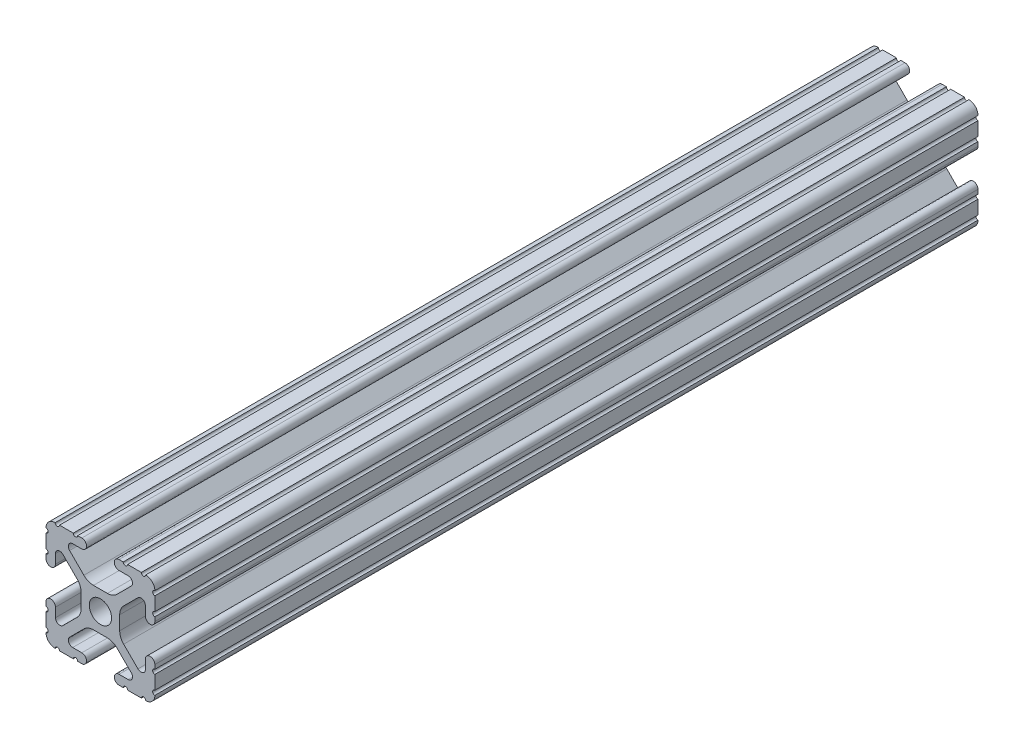
from build123d import *

# Parameters (mm, degrees)
SKETCH1_R           = 2.6035
BOSS_EXTRUDE1_DEPTH = 96.04375


with BuildPart() as part:
    # Sketch1 → Boss-Extrude1 (new body, symmetric)
    with BuildSketch(Plane(origin=(0, 0, -450.85), x_dir=(-1, 0, 0), z_dir=(0, 0, -1))):
        with BuildLine():
            Line((12.7, -9.5504), (12.7, -6.3330836))
            ThreePointArc((12.7, -6.3330836), (12.192, -5.8250836), (12.7, -5.3170836))
            Line((12.7, -5.3170836), (12.7, -4.3434))
            ThreePointArc((12.7, -4.3434), (11.5951, -3.2385), (10.4902, -4.3434))
            Line((10.4902, -4.3434), (10.4902, -6.474794456))
            ThreePointArc((10.4902, -6.474794456), (9.863006367, -7.413456061), (8.75577951, -7.193214945))
            Line((8.75577951, -7.193214945), (5.42573597, -3.863171405))
            ThreePointArc((5.42573597, -3.863171405), (4.737482484, -2.833127272), (4.4958, -1.618107374))
            Line((4.4958, -1.618107374), (4.4958, 1.618107374))
            ThreePointArc((4.4958, 1.618107374), (4.737482484, 2.833127272), (5.42573597, 3.863171405))
            Line((5.42573597, 3.863171405), (8.75577951, 7.193214945))
            ThreePointArc((8.75577951, 7.193214945), (9.863006367, 7.413456061), (10.4902, 6.474794456))
            Line((10.4902, 6.474794456), (10.4902, 4.343399971))
            ThreePointArc((10.4902, 4.343399971), (11.5951, 3.238499971), (12.7, 4.343399971))
            Line((12.7, 4.343399971), (12.7, 5.3170836))
            ThreePointArc((12.7, 5.3170836), (12.192, 5.8250836), (12.7, 6.3330836))
            Line((12.7, 6.3330836), (12.7, 9.5504))
            ThreePointArc((12.7, 9.5504), (12.192000006, 10.058323491), (12.699846982, 10.566399977))
            ThreePointArc((12.699846982, 10.566399977), (12.082522516, 12.082522516), (10.566399977, 12.699846982))
            ThreePointArc((10.566399977, 12.699846982), (10.058323491, 12.192000006), (9.5504, 12.7))
            Line((9.5504, 12.7), (6.3330836, 12.7))
            ThreePointArc((6.3330836, 12.7), (5.8250836, 12.192), (5.3170836, 12.7))
            Line((5.3170836, 12.7), (4.3434, 12.7))
            ThreePointArc((4.3434, 12.7), (3.2385, 11.5951), (4.3434, 10.4902))
            Line((4.3434, 10.4902), (6.474794456, 10.4902))
            ThreePointArc((6.474794456, 10.4902), (7.413456061, 9.863006367), (7.193214945, 8.75577951))
            Line((7.193214945, 8.75577951), (3.863171405, 5.42573597))
            ThreePointArc((3.863171405, 5.42573597), (2.833127272, 4.737482484), (1.618107374, 4.4958))
            Line((1.618107374, 4.4958), (-1.618107374, 4.4958))
            ThreePointArc((-1.618107374, 4.4958), (-2.833127272, 4.737482484), (-3.863171405, 5.42573597))
            Line((-3.863171405, 5.42573597), (-7.193214945, 8.75577951))
            ThreePointArc((-7.193214945, 8.75577951), (-7.413456061, 9.863006367), (-6.474794456, 10.4902))
            Line((-6.474794456, 10.4902), (-4.343399971, 10.4902))
            ThreePointArc((-4.343399971, 10.4902), (-3.238499971, 11.5951), (-4.343399971, 12.7))
            Line((-4.343399971, 12.7), (-5.3170836, 12.7))
            ThreePointArc((-5.3170836, 12.7), (-5.8250836, 12.192), (-6.3330836, 12.7))
            Line((-6.3330836, 12.7), (-9.5504, 12.7))
            ThreePointArc((-9.5504, 12.7), (-10.058323491, 12.192000006), (-10.566399977, 12.699846982))
            ThreePointArc((-10.566399977, 12.699846982), (-12.082522516, 12.082522516), (-12.699846982, 10.566399977))
            ThreePointArc((-12.699846982, 10.566399977), (-12.192000006, 10.058323491), (-12.7, 9.5504))
            Line((-12.7, 9.5504), (-12.7, 6.3330836))
            ThreePointArc((-12.7, 6.3330836), (-12.192, 5.8250836), (-12.7, 5.3170836))
            Line((-12.7, 5.3170836), (-12.7, 4.3434))
            ThreePointArc((-12.7, 4.3434), (-11.5951, 3.2385), (-10.4902, 4.3434))
            Line((-10.4902, 4.3434), (-10.4902, 6.474794456))
            ThreePointArc((-10.4902, 6.474794456), (-9.863006367, 7.413456061), (-8.75577951, 7.193214945))
            Line((-8.75577951, 7.193214945), (-5.42573597, 3.863171405))
            ThreePointArc((-5.42573597, 3.863171405), (-4.737482484, 2.833127272), (-4.4958, 1.618107374))
            Line((-4.4958, 1.618107374), (-4.4958, -1.618107374))
            ThreePointArc((-4.4958, -1.618107374), (-4.737482484, -2.833127272), (-5.42573597, -3.863171405))
            Line((-5.42573597, -3.863171405), (-8.75577951, -7.193214945))
            ThreePointArc((-8.75577951, -7.193214945), (-9.863006367, -7.413456061), (-10.4902, -6.474794456))
            Line((-10.4902, -6.474794456), (-10.4902, -4.343399971))
            ThreePointArc((-10.4902, -4.343399971), (-11.5951, -3.238499971), (-12.7, -4.343399971))
            Line((-12.7, -4.343399971), (-12.7, -5.3170836))
            ThreePointArc((-12.7, -5.3170836), (-12.192, -5.8250836), (-12.7, -6.3330836))
            Line((-12.7, -6.3330836), (-12.7, -9.5504))
            ThreePointArc((-12.7, -9.5504), (-12.192000006, -10.058323491), (-12.699846982, -10.566399977))
            ThreePointArc((-12.699846982, -10.566399977), (-12.082522516, -12.082522516), (-10.566399977, -12.699846982))
            ThreePointArc((-10.566399977, -12.699846982), (-10.058323491, -12.192000006), (-9.5504, -12.7))
            Line((-9.5504, -12.7), (-6.3330836, -12.7))
            ThreePointArc((-6.3330836, -12.7), (-5.8250836, -12.192), (-5.3170836, -12.7))
            Line((-5.3170836, -12.7), (-4.3434, -12.7))
            ThreePointArc((-4.3434, -12.7), (-3.2385, -11.5951), (-4.3434, -10.4902))
            Line((-4.3434, -10.4902), (-6.474794456, -10.4902))
            ThreePointArc((-6.474794456, -10.4902), (-7.413456061, -9.863006367), (-7.193214945, -8.75577951))
            Line((-7.193214945, -8.75577951), (-3.863171405, -5.42573597))
            ThreePointArc((-3.863171405, -5.42573597), (-2.833127272, -4.737482484), (-1.618107374, -4.4958))
            Line((-1.618107374, -4.4958), (1.618107374, -4.4958))
            ThreePointArc((1.618107374, -4.4958), (2.833127272, -4.737482484), (3.863171405, -5.42573597))
            Line((3.863171405, -5.42573597), (7.193214945, -8.75577951))
            ThreePointArc((7.193214945, -8.75577951), (7.413456061, -9.863006367), (6.474794456, -10.4902))
            Line((6.474794456, -10.4902), (4.343399971, -10.4902))
            ThreePointArc((4.343399971, -10.4902), (3.238499971, -11.5951), (4.343399971, -12.7))
            Line((4.343399971, -12.7), (5.3170836, -12.7))
            ThreePointArc((5.3170836, -12.7), (5.8250836, -12.192), (6.3330836, -12.7))
            Line((6.3330836, -12.7), (9.5504, -12.7))
            ThreePointArc((9.5504, -12.7), (10.058323491, -12.192000006), (10.566399977, -12.699846982))
            ThreePointArc((10.566399977, -12.699846982), (12.082522516, -12.082522516), (12.699846982, -10.566399977))
            ThreePointArc((12.699846982, -10.566399977), (12.192000006, -10.058323491), (12.7, -9.5504))
        make_face()
        Circle(SKETCH1_R, mode=Mode.SUBTRACT)
    extrude(amount=BOSS_EXTRUDE1_DEPTH, both=True)


solid = part.part
